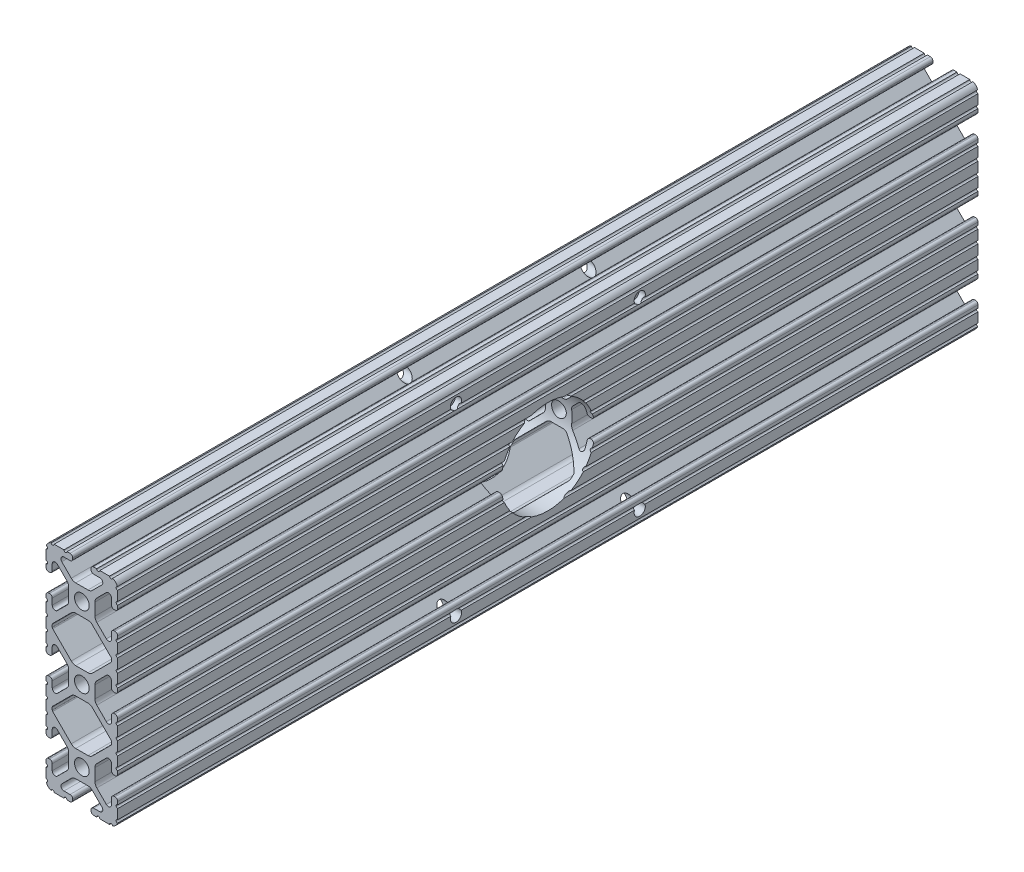
from build123d import *

# Parameters (mm, degrees)
BOSS_EXTRUDE1_DEPTH     = 152.4
SKETCH5_R               = 0.55245
CUT_EXTRUDE1_DEPTH      = 158.602855304
CUT_EXTRUDE1_DEPTH_BACK = 158.602855304
BOSS_EXTRUDE2_DEPTH     = 152.4
CUT_EXTRUDE2_DEPTH      = 158.602855304
CUT_EXTRUDE2_DEPTH_BACK = 158.602855304
SKETCH8_R               = 1.9812
SKETCH8_R_2             = 16.637
CUT_EXTRUDE3_DEPTH      = 160.130543894


with BuildPart() as part:
    # Sketch4 → Boss-Extrude1 (new, symmetric)
    with BuildSketch(Plane.XY):
        with BuildLine():
            Line((4.190365, -38.1), (10.11729625, -38.1))
            ThreePointArc((10.11729625, -38.1), (11.943543585, -37.343543585), (12.7, -35.51729625))
            Line((12.7, -35.51729625), (12.7, -29.590365))
            ThreePointArc((12.7, -29.590365), (12.42492494, -28.92627506), (11.760835, -28.6512))
            Line((11.760835, -28.6512), (11.429365, -28.6512))
            ThreePointArc((11.429365, -28.6512), (10.76527506, -28.92627506), (10.4902, -29.590365))
            Line((10.4902, -29.590365), (10.4902, -31.748478019))
            ThreePointArc((10.4902, -31.748478019), (9.830707141, -32.735478831), (8.666460301, -32.503895736))
            Line((8.666460301, -32.503895736), (5.299899128, -29.137334563))
            ThreePointArc((5.299899128, -29.137334563), (4.817571085, -28.415479634), (4.6482, -27.56399369))
            Line((4.6482, -27.56399369), (4.6482, -25.4))
            Line((4.6482, -25.4), (2.6035, -25.4))
            ThreePointArc((2.6035, -25.4), (1.840952505, -27.240952505), (0, -28.0035))
            Line((0, -28.0035), (0, -30.0482))
            Line((0, -30.0482), (2.16399369, -30.0482))
            ThreePointArc((2.16399369, -30.0482), (3.015479634, -30.217571085), (3.737334563, -30.699899128))
            Line((3.737334563, -30.699899128), (7.103895736, -34.066460301))
            ThreePointArc((7.103895736, -34.066460301), (7.335478831, -35.230707141), (6.348478019, -35.8902))
            Line((6.348478019, -35.8902), (4.190365, -35.8902))
            ThreePointArc((4.190365, -35.8902), (3.52627506, -36.16527506), (3.2512, -36.829365))
            Line((3.2512, -36.829365), (3.2512, -37.160835))
            ThreePointArc((3.2512, -37.160835), (3.52627506, -37.82492494), (4.190365, -38.1))
        make_face()
    extrude(amount=BOSS_EXTRUDE1_DEPTH, both=True)

    # Sketch5 → Cut-Extrude1 (cut, two sides)
    with BuildSketch(Plane.XY) as cut_extrude1_sk:
        with Locations((10.356153152, -38.1)):
            Circle(SKETCH5_R)
        with Locations((5.796028019, -38.1)):
            Circle(SKETCH5_R)
        with Locations((12.7, -35.756153152)):
            Circle(SKETCH5_R)
        with Locations((12.7, -31.196028019)):
            Circle(SKETCH5_R)
    extrude(amount=CUT_EXTRUDE1_DEPTH, mode=Mode.SUBTRACT)
    extrude(cut_extrude1_sk.sketch, amount=-CUT_EXTRUDE1_DEPTH_BACK, mode=Mode.SUBTRACT)

    # Mirror1: part across plane


with BuildPart() as part_1:
    add(part.part)
    add(part.part.mirror(Plane(origin=(4.6482, -25.4, 152.4), x_dir=(0, 0, 1), z_dir=(0, -1, 0))))

    # Sketch6 → Boss-Extrude2 (add, symmetric)
    with BuildSketch(Plane.XY):
        with BuildLine():
            Line((12.7, -14.491396848), (12.7, -12.7))
            Line((12.7, -12.7), (9.803703152, -12.7))
            Line((9.803703152, -12.7), (9.803703152, -15.596296848))
            Line((9.803703152, -15.596296848), (12.7, -15.596296848))
            ThreePointArc((12.7, -15.596296848), (12.14755, -15.043846848), (12.7, -14.491396848))
        make_face()
    extrude(amount=BOSS_EXTRUDE2_DEPTH, both=True)

    # Sketch7 → Cut-Extrude2 (cut, two sides)
    with BuildSketch(Plane.XY) as cut_extrude2_sk:
        with BuildLine():
            Line((5.420615149, -18.416820286), (10.328391141, -13.509044294))
            ThreePointArc((10.328391141, -13.509044294), (10.448147248, -13.329816615), (10.4902, -13.118403152))
            Line((10.4902, -13.118403152), (10.4902, -12.7))
            Line((10.4902, -12.7), (0, -12.7))
            Line((0, -12.7), (5.420615149, -18.416820286))
        make_face()
    extrude(amount=CUT_EXTRUDE2_DEPTH, mode=Mode.SUBTRACT)
    extrude(cut_extrude2_sk.sketch, amount=-CUT_EXTRUDE2_DEPTH_BACK, mode=Mode.SUBTRACT)

    # Mirror2: part across plane


with BuildPart() as part_2:
    add(part_1.part)
    add(part_1.part.mirror(Plane(origin=(4.190365, -12.7, 152.4), x_dir=(0, 0, 1), z_dir=(0, -1, 0))))

    # SurfaceCut1
    split(bisect_by=Plane(origin=(0, 0, 0), x_dir=(1, 0, 0), z_dir=(0, 1, 0)), keep=Keep.BOTTOM)

    # Mirror3: part across plane


with BuildPart() as part_3:
    add(part_2.part)
    add(part_2.part.mirror(Plane(origin=(0, 0, 0), x_dir=(0, 0, 1), z_dir=(1, 0, 0))))

    # Mirror4: part across plane


with BuildPart() as part_4:
    add(part_3.part)
    add(part_3.part.mirror(Plane.ZX))

    # Sketch8 → Cut-Extrude3 (cut, through all)
    with BuildSketch(Plane.ZY.offset(12.7)):
        with Locations(Location((-32.5501, 32.5501, 0), (0, 0, 336.13303643))):
            Circle(SKETCH8_R)
        with Locations(Location((32.5501, 32.5501, 0), (0, 0, 336.13303643))):
            Circle(SKETCH8_R)
        with Locations(Location((32.5501, -32.5501, 0), (0, 0, 23.86696357))):
            Circle(SKETCH8_R)
        with Locations(Location((-32.5501, -32.5501, 0), (0, 0, 23.86696357))):
            Circle(SKETCH8_R)
        with Locations(Location((0, 0, 0), (0, 0, 7.473703708))):
            Circle(SKETCH8_R_2)
    extrude(amount=-CUT_EXTRUDE3_DEPTH, mode=Mode.SUBTRACT)


solid = part_4.part
